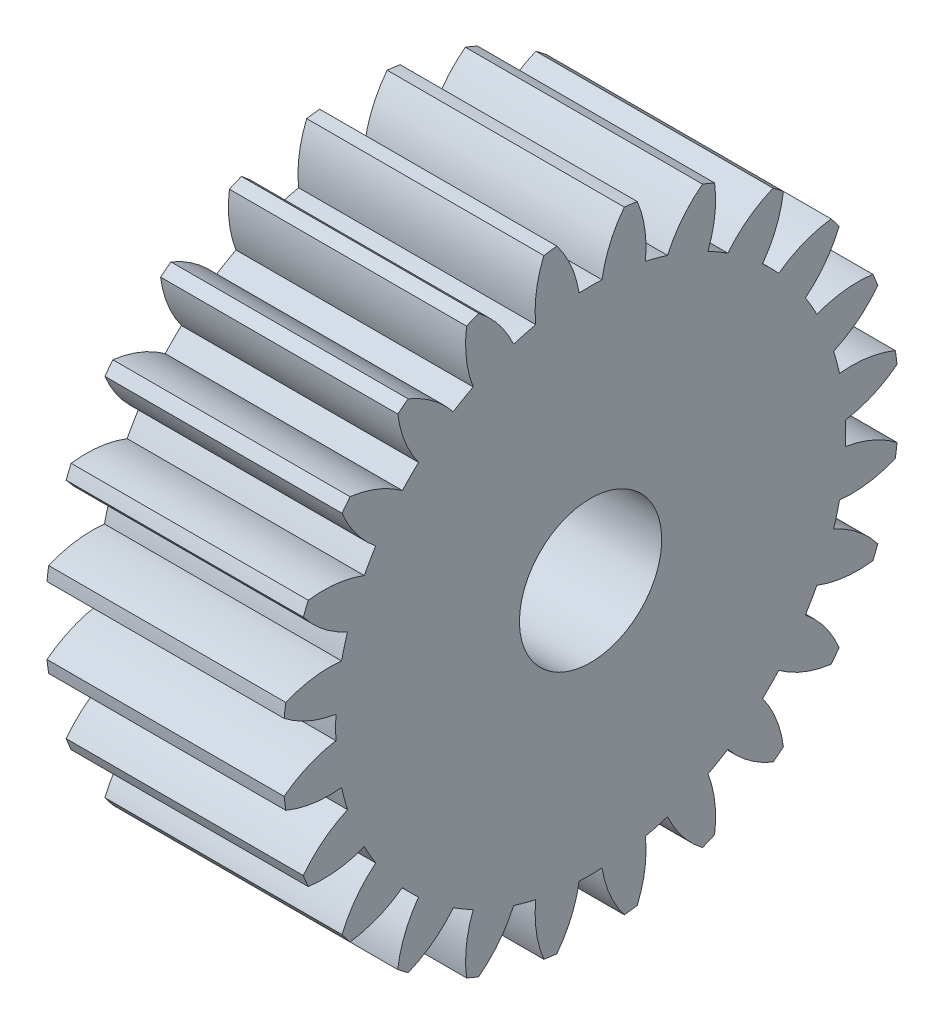
from build123d import *

# Parameters (mm, degrees)
BASPROSKE_W     = 10
BASPROSKE_H     = 13
TOOTHCUT_DEPTH  = 21.928449536
TEETHCUTS_COUNT = 24
TEETHCUTS_ANGLE = 345
BORSKE_R        = 3
BORE_DEPTH      = 50.0000508


with BuildPart() as part:
    # BasProSke → Base-Revolve (revolve)
    with BuildSketch(Plane(origin=(0, 0, 0), x_dir=(1, 0, 0), z_dir=(0, 1, 0)), mode=Mode.PRIVATE) as base_revolve_sk:
        with Locations((5, 6.5)):
            Rectangle(BASPROSKE_W, BASPROSKE_H)
    revolve(base_revolve_sk.sketch.rotate(Axis((-10, 0, 0), (1, 0, 0)), 180), axis=Axis((-10, 0, 0), (1, 0, 0)))

    # TooCutSke → ToothCut (cut, through all)
    with BuildSketch(Plane(origin=(0, 0, 0), x_dir=(0, 0, -1), z_dir=(1, 0, 0))):
        with BuildLine():
            ThreePointArc((0.483448384, 10.738122679), (0, 10.749), (-0.483448384, 10.738122679))
            ThreePointArc((-0.483448384, 10.738122679), (-0.821636462, 11.902754369), (-1.44092227, 12.945454344))
            ThreePointArc((-1.44092227, 12.945454344), (0, 13.0254), (1.44092227, 12.945454344))
            ThreePointArc((1.44092227, 12.945454344), (0.821636462, 11.902754369), (0.483448384, 10.738122679))
        make_face()
    toothcut = extrude(amount=TOOTHCUT_DEPTH, mode=Mode.SUBTRACT)

    # TeethCuts: ToothCut ×24 about axis
    teethcuts_axis = Axis((-10, 0, 0), (1, 0, 0))
    for i in range(1, TEETHCUTS_COUNT):
        add(toothcut.rotate(teethcuts_axis, i * TEETHCUTS_ANGLE / (TEETHCUTS_COUNT - 1)), mode=Mode.SUBTRACT)

    # BorSke → Bore (cut, symmetric)
    with BuildSketch(Plane(origin=(0, 0, 0), x_dir=(0, 0, -1), z_dir=(1, 0, 0))):
        with Locations(Location((0, 0, 0), (0, 0, 180))):
            Circle(BORSKE_R)
    extrude(amount=BORE_DEPTH, both=True, mode=Mode.SUBTRACT)


solid = part.part
